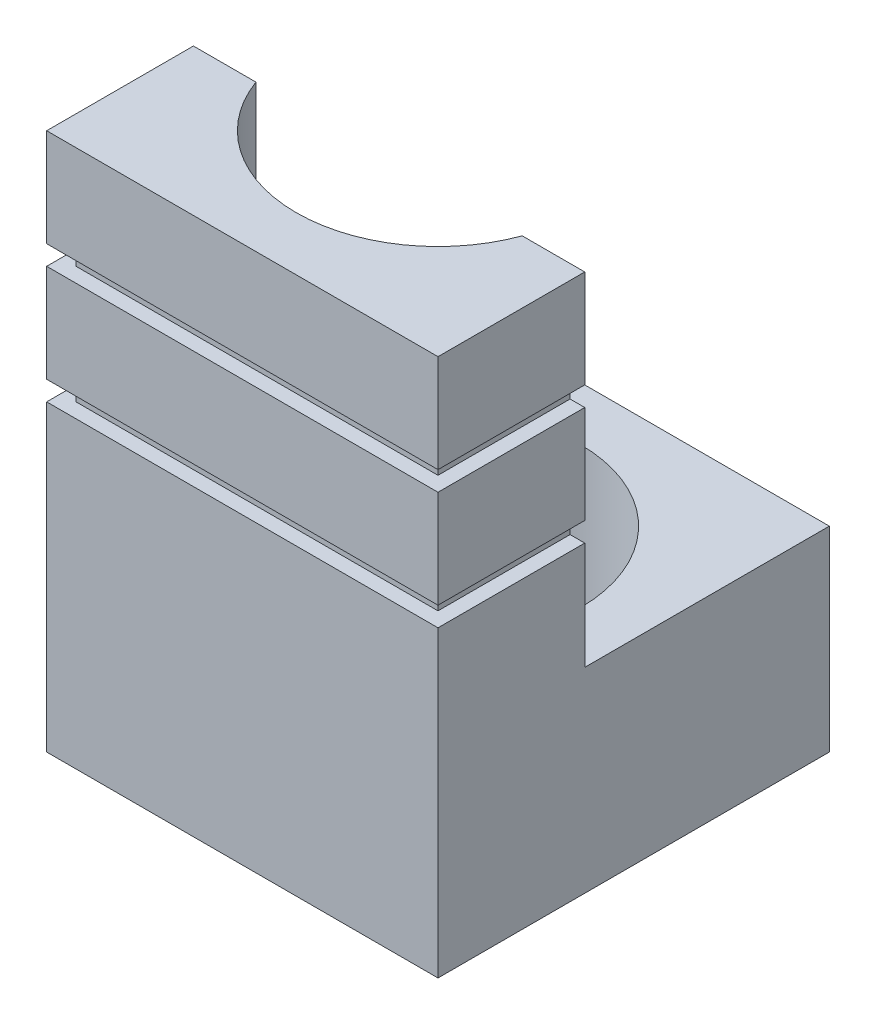
from build123d import *

# Parameters (mm, degrees)
BOSS_EXTRUDE2_DEPTH = 80
SKETCH5_R           = 29
CUT_EXTRUDE1_DEPTH  = 100
SKETCH6_R           = 24
CUT_EXTRUDE2_DEPTH  = 111
SKETCH7_W           = 30
SKETCH7_H           = 4
CUT_EXTRUDE3_DEPTH  = 3
SKETCH8_W           = 30
SKETCH8_H           = 4
CUT_EXTRUDE4_DEPTH  = 3
SKETCH9_W           = 74
SKETCH9_H           = 4
CUT_EXTRUDE5_DEPTH  = 3


with BuildPart() as part:
    # Sketch4 → Boss-Extrude2 (new body)
    with BuildSketch(Plane(origin=(0, 0, 0), x_dir=(0, 0, -1), z_dir=(1, 0, 0))):
        Polygon((0, 0), (80, 0), (80, 40), (30, 40), (30, 110), (0, 110), align=None)
    extrude(amount=BOSS_EXTRUDE2_DEPTH)

    # Sketch5 → Cut-Extrude1 (cut)
    with BuildSketch(Plane(origin=(0, 110, 0), x_dir=(1, 0, 0), z_dir=(0, 1, 0))):
        with Locations((40, 40)):
            Circle(SKETCH5_R)
    extrude(amount=-CUT_EXTRUDE1_DEPTH, mode=Mode.SUBTRACT)

    # Sketch6 → Cut-Extrude2 (cut, through all)
    with BuildSketch(Plane.XZ):
        with Locations((40, -40)):
            Circle(SKETCH6_R)
    extrude(amount=-CUT_EXTRUDE2_DEPTH, mode=Mode.SUBTRACT)

    # Sketch7 → Cut-Extrude3 (cut)
    with BuildSketch(Plane(origin=(80, 0, 0), x_dir=(0, 0, -1), z_dir=(1, 0, 0))):
        with Locations((15, 88)):
            Rectangle(SKETCH7_W, SKETCH7_H)
        with Locations((15, 64)):
            Rectangle(SKETCH7_W, SKETCH7_H)
    extrude(amount=-CUT_EXTRUDE3_DEPTH, mode=Mode.SUBTRACT)

    # Sketch8 → Cut-Extrude4 (cut)
    with BuildSketch(Plane.ZY):
        with Locations((-15, 88)):
            Rectangle(SKETCH8_W, SKETCH8_H)
        with Locations((-15, 64)):
            Rectangle(SKETCH8_W, SKETCH8_H)
    extrude(amount=-CUT_EXTRUDE4_DEPTH, mode=Mode.SUBTRACT)

    # Sketch9 → Cut-Extrude5 (cut)
    with BuildSketch(Plane.XY):
        with Locations((40, 88)):
            Rectangle(SKETCH9_W, SKETCH9_H)
        with Locations((40, 64)):
            Rectangle(SKETCH9_W, SKETCH9_H)
    extrude(amount=-CUT_EXTRUDE5_DEPTH, mode=Mode.SUBTRACT)


solid = part.part
